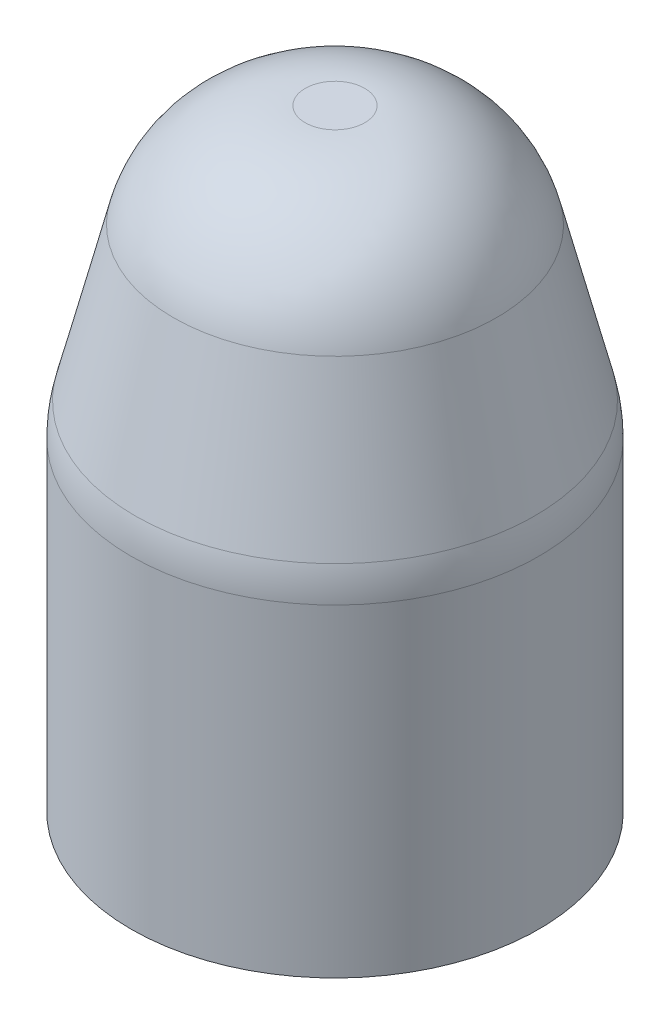
from build123d import *

# Parameters (mm, degrees)
FILLET1_R = 2
FILLET2_R = 2


with BuildPart() as part:
    # Sketch1 → Revolve1 (revolve)
    with BuildSketch(Plane.XY):
        Polygon((0, 0), (3, 0), (3, 5), (2, 9), (0, 9), align=None)
    revolve(axis=Axis((0, 9, 0), (0, -1, 0)))

    # Fillet1
    fillet1_edges = [part.edges().sort_by_distance(p)[0] for p in [
        (-2, 9, 0),
    ]]
    fillet(fillet1_edges, radius=FILLET1_R)

    # Fillet2
    fillet2_edges = [part.edges().sort_by_distance(p)[0] for p in [
        (-3, 5, 0),
    ]]
    fillet(fillet2_edges, radius=FILLET2_R)


solid = part.part
